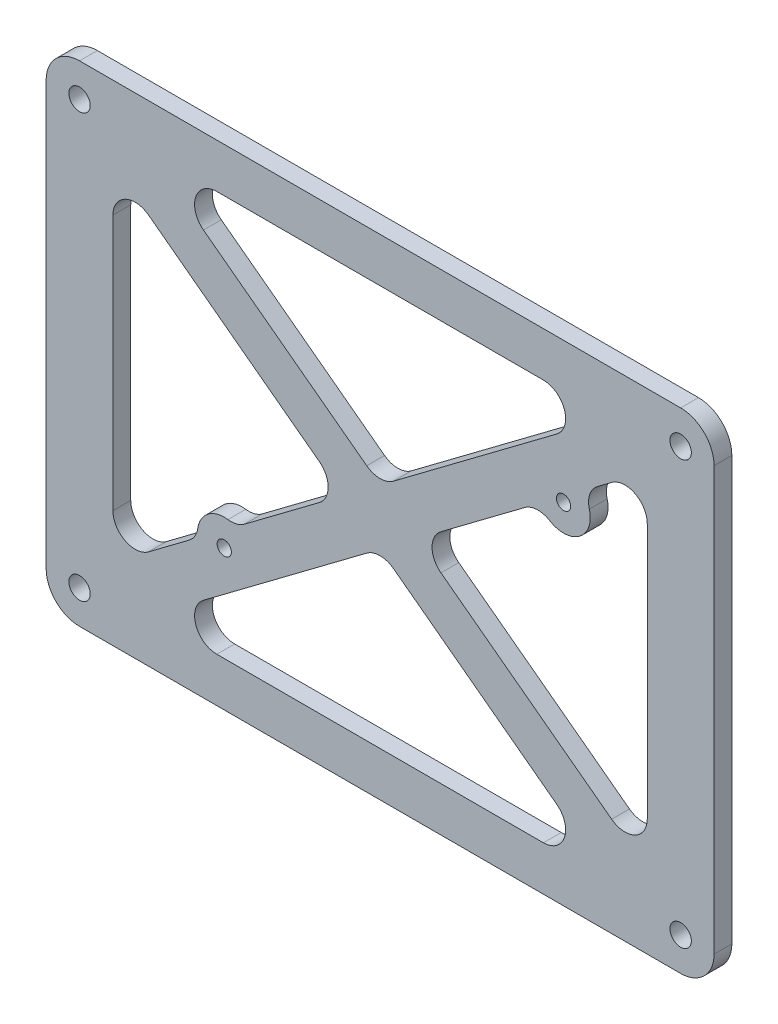
from build123d import *

# Parameters (mm, degrees)
SKETCH_1_W           = 110
SKETCH_1_H           = 150
EXTRUDE_1_DEPTH      = 4
HOLE_WIZARD_M4_1_D   = 4.8
HOLE_WIZARD_M3_1_D   = 3.2
SKETCH_6_OUTSIDE_W   = 189.21
SKETCH_6_OUTSIDE_H   = 149.21
SKETCH_6_OUTSIDE_W_2 = 150
SKETCH_6_OUTSIDE_H_2 = 110
CUT_EXTRUDE_1_DEPTH  = 5
FILLET_3_R           = 5
FILLET_1_R           = 7.5


with BuildPart() as part:
    # ｽｹｯﾁ1 → ﾎﾞｽ - 押し出し1 (new body)
    with BuildSketch(Plane(origin=(0, 0, 0), x_dir=(0, 1, 0), z_dir=(0, 0, 1))):
        with Locations((55, 75)):
            Rectangle(SKETCH_1_W, SKETCH_1_H)
    extrude(amount=EXTRUDE_1_DEPTH)

    # M4 すきま穴1 (through all)
    with Locations(Plane.XY.offset(4)):
        with Locations((-142.5, 102.5), (-142.5, 7.5), (-7.5, 102.5), (-7.5, 7.5)):
            Hole(HOLE_WIZARD_M4_1_D / 2)

    # M3 すきま穴1 (through all)
    with Locations(Plane.XY.offset(4)):
        with Locations((-110, 31.5), (-33.8, 78.49)):
            Hole(HOLE_WIZARD_M3_1_D / 2)

    # ｽｹｯﾁ6 outside → ｶｯﾄ - 押し出し1 (cut, through all)
    with BuildSketch(Plane.XY.offset(4)):
        with Locations((-75, 55)):
            Rectangle(SKETCH_6_OUTSIDE_W, SKETCH_6_OUTSIDE_H)
        with Locations((-75, 55)):
            Rectangle(SKETCH_6_OUTSIDE_W_2, SKETCH_6_OUTSIDE_H_2, mode=Mode.SUBTRACT)
        Polygon((-126.666666667, 10), (-23.333333333, 10), (-75, 48.75), align=None)
        with BuildLine():
            Line((-135, 16.25), (-135, 93.75))
            Line((-135, 93.75), (-83.333333333, 55))
            Line((-83.333333333, 55), (-107.434720268, 36.923959799))
            ThreePointArc((-107.434720268, 36.923959799), (-113.6, 36.3), (-115.925279732, 30.556040201))
            Line((-115.925279732, 30.556040201), (-135, 16.25))
        make_face()
        Polygon((-126.666666667, 100), (-23.333333333, 100), (-75, 61.25), align=None)
        with BuildLine():
            Line((-15, 16.25), (-15, 93.75))
            Line((-15, 93.75), (-29.614559787, 82.78908016))
            ThreePointArc((-29.614559787, 82.78908016), (-30.2, 73.69), (-39.099040213, 75.67571984))
            Line((-39.099040213, 75.67571984), (-66.666666667, 55))
            Line((-66.666666667, 55), (-15, 16.25))
        make_face()
    extrude(amount=-CUT_EXTRUDE_1_DEPTH, mode=Mode.SUBTRACT)

    # ﾌｨﾚｯﾄ3
    fillet_3_edges = [part.edges().sort_by_distance(p)[0] for p in [
        (-75, 48.75, 2),
        (-23.333333333, 10, 2),
        (-126.666666667, 10, 2),
        (-135, 93.75, 2),
        (-83.333333333, 55, 2),
        (-107.434720268, 36.923959799, 2),
        (-115.925279732, 30.556040201, 2),
        (-135, 16.25, 2),
        (-15, 16.25, 2),
        (-66.666666667, 55, 2),
        (-39.099040213, 75.67571984, 2),
        (-29.614559787, 82.78908016, 2),
        (-15, 93.75, 2),
        (-75, 61.25, 2),
        (-126.666666667, 100, 2),
        (-23.333333333, 100, 2),
    ]]
    fillet(fillet_3_edges, radius=FILLET_3_R)

    # ﾌｨﾚｯﾄ1
    fillet_1_edges = [part.edges().sort_by_distance(p)[0] for p in [
        (-150, 0, 2),
        (-150, 110, 2),
        (0, 110, 2),
        (0, 0, 2),
    ]]
    fillet(fillet_1_edges, radius=FILLET_1_R)


solid = part.part
